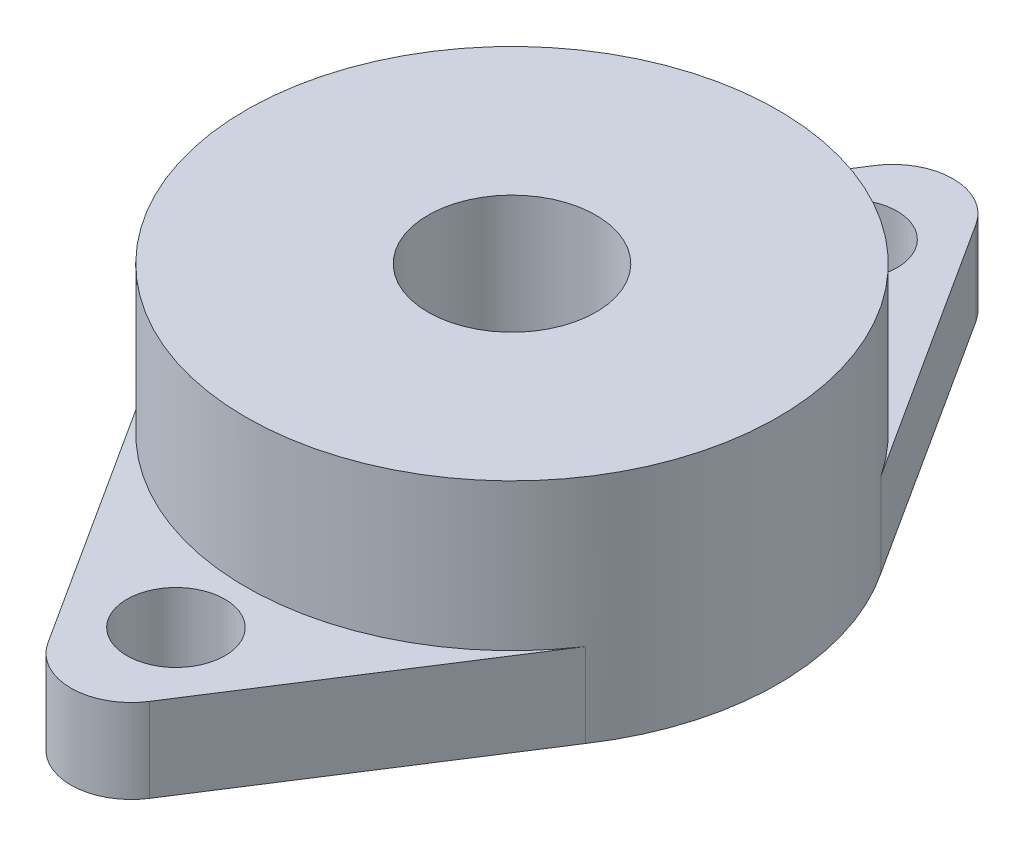
from build123d import *

# Parameters (mm, degrees)
SKETCH1_R           = 19
BOSS_EXTRUDE1_DEPTH = 16.5
BOSS_EXTRUDE2_DEPTH = 6
SKETCH3_R           = 6
CUT_EXTRUDE1_DEPTH  = 41.317490001
SKETCH4_R           = 3.5
CUT_EXTRUDE2_DEPTH  = 39.255718527


with BuildPart() as part:
    # Sketch1 → Boss-Extrude1 (new body)
    with BuildSketch(Plane(origin=(0, 0, 0), x_dir=(1, 0, 0), z_dir=(0, 1, 0))):
        with Locations(Location((0, 0, 0), (0, 0, 270))):
            Circle(SKETCH1_R)
    extrude(amount=BOSS_EXTRUDE1_DEPTH)

    # Sketch2 → Boss-Extrude2 (add)
    with BuildSketch(Plane(origin=(0, 0, 0), x_dir=(1, 0, 0), z_dir=(0, 1, 0))):
        with BuildLine():
            Line((0, 10.549840688), (0, 22.89723562))
            ThreePointArc((0, 22.89723562), (-3.774822907, 25.136434317), (-3.61947725, 29.522681746))
            Line((-3.61947725, 29.522681746), (-15.801925878, 10.549840688))
            Line((-15.801925878, 10.549840688), (0, 10.549840688))
        make_face()
        with BuildLine():
            ThreePointArc((4.30138219, 27.19861781), (3.041536515, 24.157081295), (0, 22.89723562))
            Line((0, 22.89723562), (0, 10.549840688))
            Line((0, 10.549840688), (15.801925878, 10.549840688))
            Line((15.801925878, 10.549840688), (3.61947725, 29.522681746))
            ThreePointArc((3.61947725, 29.522681746), (4.127386808, 28.409636753), (4.30138219, 27.19861781))
        make_face()
        with BuildLine():
            ThreePointArc((3.61947725, 29.522681746), (2.062183493, 30.973440718), (0, 31.5))
            Line((0, 31.5), (0, 22.89723562))
            ThreePointArc((0, 22.89723562), (3.041536515, 24.157081295), (4.30138219, 27.19861781))
            ThreePointArc((4.30138219, 27.19861781), (4.127386808, 28.409636753), (3.61947725, 29.522681746))
        make_face()
        with BuildLine():
            Line((0, 22.89723562), (0, 31.5))
            ThreePointArc((0, 31.5), (-2.062183493, 30.973440718), (-3.61947725, 29.522681746))
            ThreePointArc((-3.61947725, 29.522681746), (-3.774822907, 25.136434317), (0, 22.89723562))
        make_face()
    boss_extrude2 = extrude(amount=BOSS_EXTRUDE2_DEPTH)

    # Sketch3 → Cut-Extrude1 (cut, through all)
    with BuildSketch(Plane(origin=(0, 16.5, 0), x_dir=(1, 0, 0), z_dir=(0, 1, 0))):
        with Locations(Location((0, 0, 0), (0, 0, 270))):
            Circle(SKETCH3_R)
    extrude(amount=-CUT_EXTRUDE1_DEPTH, mode=Mode.SUBTRACT)

    # Sketch4 → Cut-Extrude2 (cut, through all)
    with BuildSketch(Plane(origin=(0, 6, 0), x_dir=(1, 0, 0), z_dir=(0, 1, 0))):
        with Locations(Location((0, 24, 0), (0, 0, 270))):
            Circle(SKETCH4_R)
    cut_extrude2 = extrude(amount=-CUT_EXTRUDE2_DEPTH, mode=Mode.SUBTRACT)

    # Mirror1: Boss-Extrude2, Cut-Extrude2 across plane
    add(boss_extrude2.mirror(Plane.XY))
    add(cut_extrude2.mirror(Plane.XY), mode=Mode.SUBTRACT)


solid = part.part
